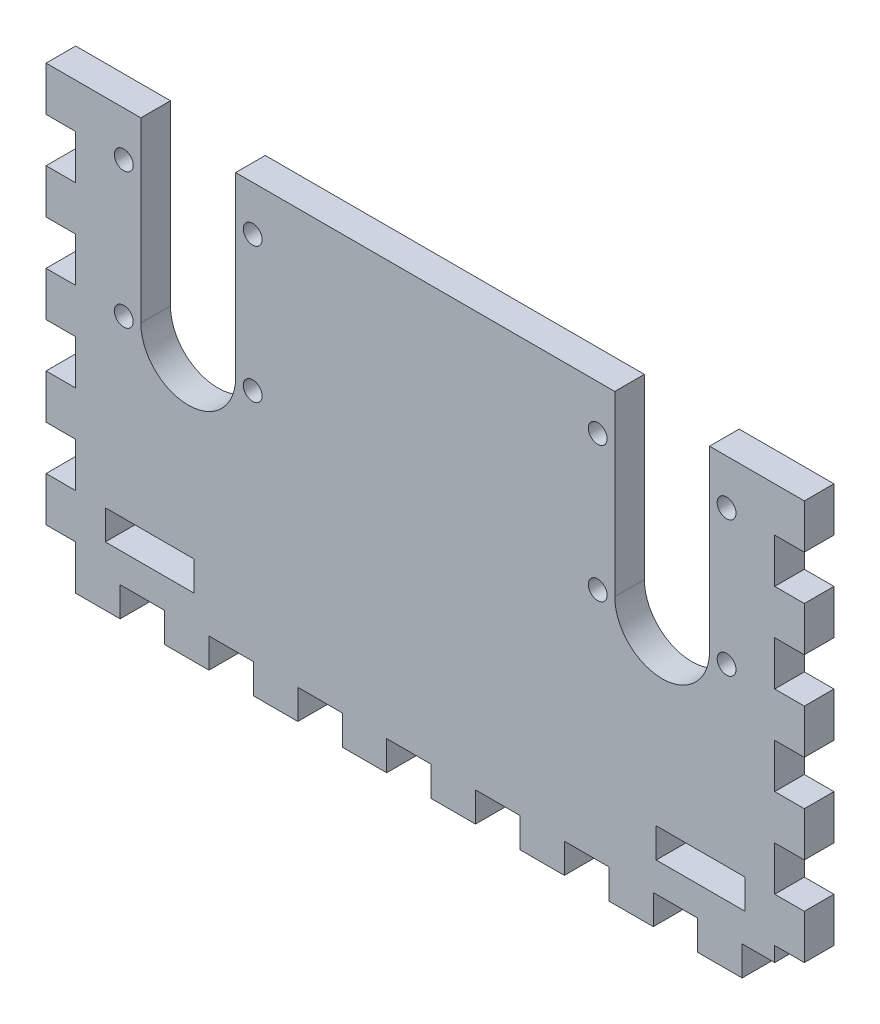
from build123d import *

# Parameters (mm, degrees)
SKETCH1_W           = 149.86
SKETCH1_H           = 88.9
SKETCH1_W_2         = 19.05
SKETCH1_H_2         = 6.35
GENERAL_SHAPE_DEPTH = 6.35
SKETCH4_R           = 2.0193
SLOT_CUT_OUTS_DEPTH = 6.35
SKETCH5_W           = 6.35
SKETCH5_H           = 9.525
SKETCH5_W_2         = 9.525
SKETCH5_H_2         = 6.35
EDGE_TEETH_DEPTH    = 6.35


with BuildPart() as part:
    # Sketch1 → General Shape (new body)
    with BuildSketch(Plane.XY):
        with Locations((74.93, -44.45)):
            Rectangle(SKETCH1_W, SKETCH1_H)
        with Locations((133.985, -79.375)):
            Rectangle(SKETCH1_W_2, SKETCH1_H_2, mode=Mode.SUBTRACT)
        with Locations((15.875, -79.375)):
            Rectangle(SKETCH1_W_2, SKETCH1_H_2, mode=Mode.SUBTRACT)
    extrude(amount=GENERAL_SHAPE_DEPTH)

    # Sketch4 → Slot Cut-Outs (cut)
    with BuildSketch(Plane.XY.offset(6.35)):
        with Locations((37.9476, -9.6266)):
            Circle(SKETCH4_R)
        with Locations((37.9476, -38.6588)):
            Circle(SKETCH4_R)
        with Locations((10.3124, -38.6588)):
            Circle(SKETCH4_R)
        with Locations((10.3124, -9.6266)):
            Circle(SKETCH4_R)
        with Locations((139.5476, -9.6266)):
            Circle(SKETCH4_R)
        with Locations((111.9124, -9.6266)):
            Circle(SKETCH4_R)
        with Locations((111.9124, -38.6588)):
            Circle(SKETCH4_R)
        with Locations((139.5476, -38.6588)):
            Circle(SKETCH4_R)
        with BuildLine():
            Line((34.29, 0), (34.29, -38.1))
            ThreePointArc((34.29, -38.1), (24.13, -48.26), (13.97, -38.1))
            Line((13.97, -38.1), (13.97, 0))
            ThreePointArc((13.97, 0), (24.13, 10.16), (34.29, 0))
        make_face()
        with BuildLine():
            Line((135.89, 0), (135.89, -38.1))
            ThreePointArc((135.89, -38.1), (125.73, -48.26), (115.57, -38.1))
            Line((115.57, -38.1), (115.57, 0))
            ThreePointArc((115.57, 0), (125.73, 10.16), (135.89, 0))
        make_face()
    extrude(amount=-SLOT_CUT_OUTS_DEPTH, mode=Mode.SUBTRACT)

    # Sketch5 → Edge Teeth (add)
    with BuildSketch(Plane.XY.offset(6.35)):
        with Locations((-3.175, -4.7625)):
            Rectangle(SKETCH5_W, SKETCH5_H)
        with Locations((-3.175, -23.8125)):
            Rectangle(SKETCH5_W, SKETCH5_H)
        with Locations((-3.175, -42.8625)):
            Rectangle(SKETCH5_W, SKETCH5_H)
        with Locations((-3.175, -61.9125)):
            Rectangle(SKETCH5_W, SKETCH5_H)
        with Locations((-3.175, -80.9625)):
            Rectangle(SKETCH5_W, SKETCH5_H)
        with Locations((153.035, -80.9625)):
            Rectangle(SKETCH5_W, SKETCH5_H)
        with Locations((153.035, -61.9125)):
            Rectangle(SKETCH5_W, SKETCH5_H)
        with Locations((153.035, -42.8625)):
            Rectangle(SKETCH5_W, SKETCH5_H)
        with Locations((153.035, -23.8125)):
            Rectangle(SKETCH5_W, SKETCH5_H)
        with Locations((153.035, -4.7625)):
            Rectangle(SKETCH5_W, SKETCH5_H)
        with Locations((23.8125, -92.075)):
            Rectangle(SKETCH5_W_2, SKETCH5_H_2)
        with Locations((4.7625, -92.075)):
            Rectangle(SKETCH5_W_2, SKETCH5_H_2)
        with Locations((42.8625, -92.075)):
            Rectangle(SKETCH5_W_2, SKETCH5_H_2)
        with Locations((61.9125, -92.075)):
            Rectangle(SKETCH5_W_2, SKETCH5_H_2)
        with Locations((80.9625, -92.075)):
            Rectangle(SKETCH5_W_2, SKETCH5_H_2)
        with Locations((100.0125, -92.075)):
            Rectangle(SKETCH5_W_2, SKETCH5_H_2)
        with Locations((119.0625, -92.075)):
            Rectangle(SKETCH5_W_2, SKETCH5_H_2)
        with Locations((138.1125, -92.075)):
            Rectangle(SKETCH5_W_2, SKETCH5_H_2)
    extrude(amount=-EDGE_TEETH_DEPTH)


solid = part.part
